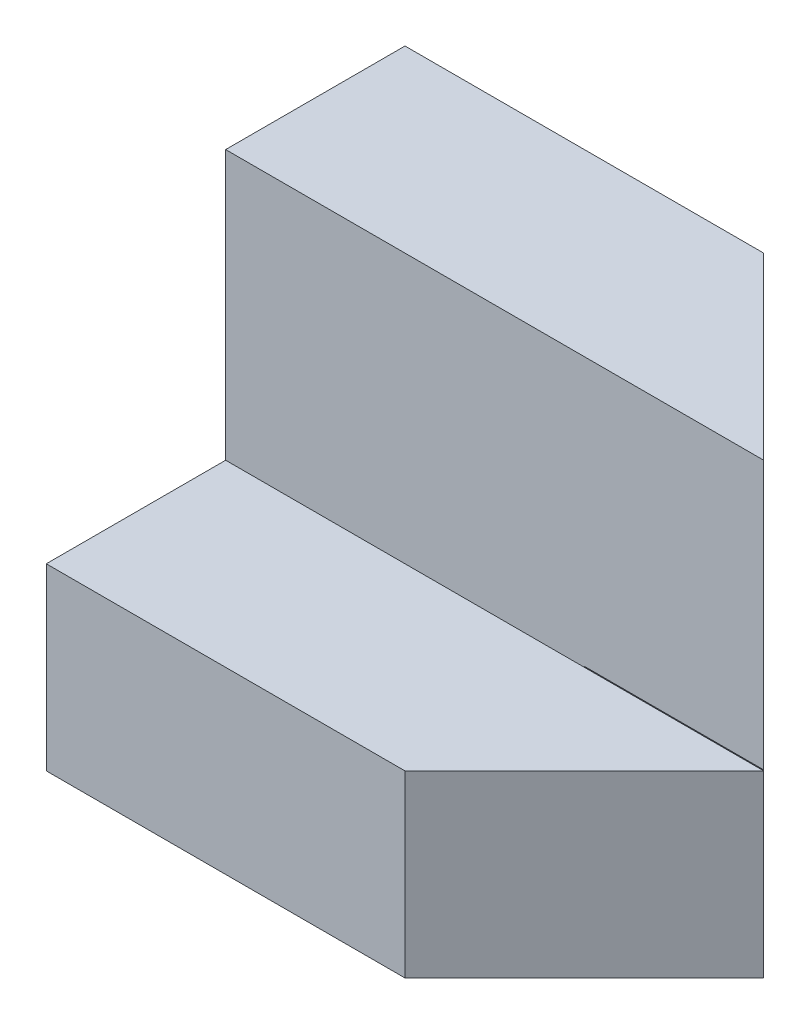
from build123d import *

# Parameters (mm, degrees)
SKETCH1_W           = 4
SKETCH1_H           = 5
BOSS_EXTRUDE1_DEPTH = 2
SKETCH2_W           = 4
SKETCH2_H           = 2
BOSS_EXTRUDE2_DEPTH = 2
BOSS_EXTRUDE3_DEPTH = 2
BOSS_EXTRUDE5_DEPTH = 2.99


with BuildPart() as part:
    # Sketch1 → Boss-Extrude1 (new body)
    with BuildSketch(Plane.XY):
        Rectangle(SKETCH1_W, SKETCH1_H)
    extrude(amount=BOSS_EXTRUDE1_DEPTH)

    # Sketch2 → Boss-Extrude2 (add)
    with BuildSketch(Plane.XY.offset(2)):
        with Locations((0, -1.5)):
            Rectangle(SKETCH2_W, SKETCH2_H)
    extrude(amount=BOSS_EXTRUDE2_DEPTH)

    # Sketch3 → Boss-Extrude3 (add)
    with BuildSketch(Plane(origin=(0, -0.5, 0), x_dir=(1, 0, 0), z_dir=(0, 1, 0))):
        Polygon((2, -4), (4, -2), (2, -2), align=None)
    extrude(amount=-BOSS_EXTRUDE3_DEPTH)

    # Sketch5 → Boss-Extrude5 (add)
    with BuildSketch(Plane(origin=(0, 2.5, 0), x_dir=(1, 0, 0), z_dir=(0, 1, 0))):
        Polygon((2, 0), (4, -2), (2, -2), align=None)
    extrude(amount=-BOSS_EXTRUDE5_DEPTH)


solid = part.part
